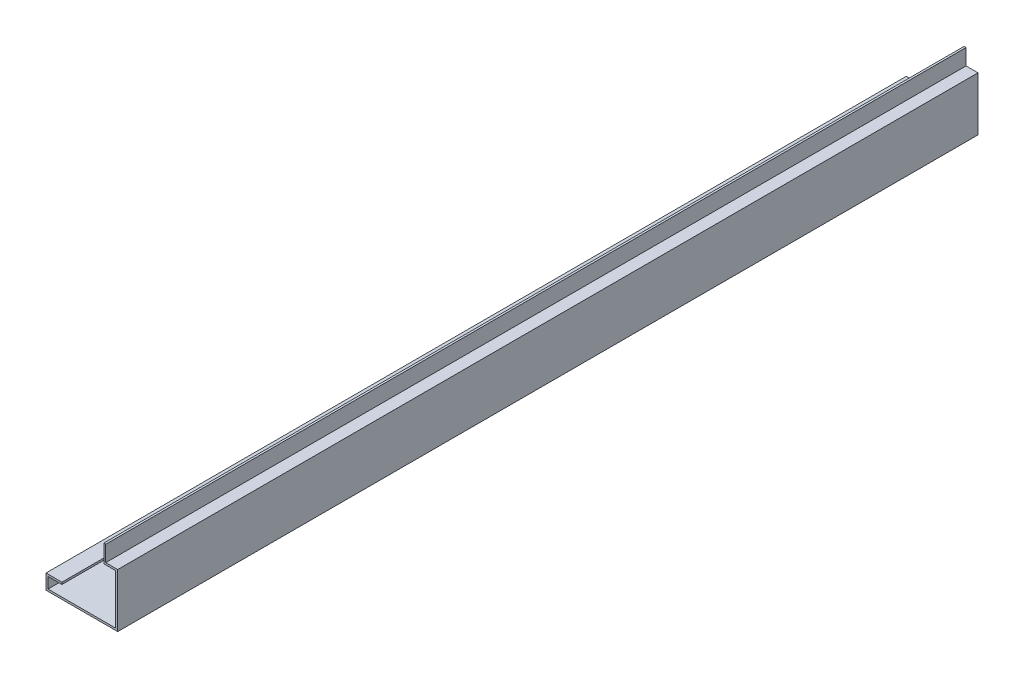
from build123d import *

# Parameters (mm, degrees)
SALIENTE_EXTRUIR1_DEPTH = 2743.2


with BuildPart() as part:
    # Croquis1 → Saliente-Extruir1 (new body)
    with BuildSketch(Plane.XY):
        Polygon((-139.7, -174.625), (-139.7, -180.975), (-184.15, -180.975), (-184.15, -215.9), (31.75, -215.9), (31.75, -57.15), (-6.35, -57.15), (-6.35, 0), (0, 0), (0, -50.8), (38.1, -50.8), (38.1, -222.25), (-190.5, -222.25), (-190.5, -174.625), align=None)
    extrude(amount=-SALIENTE_EXTRUIR1_DEPTH)


solid = part.part
